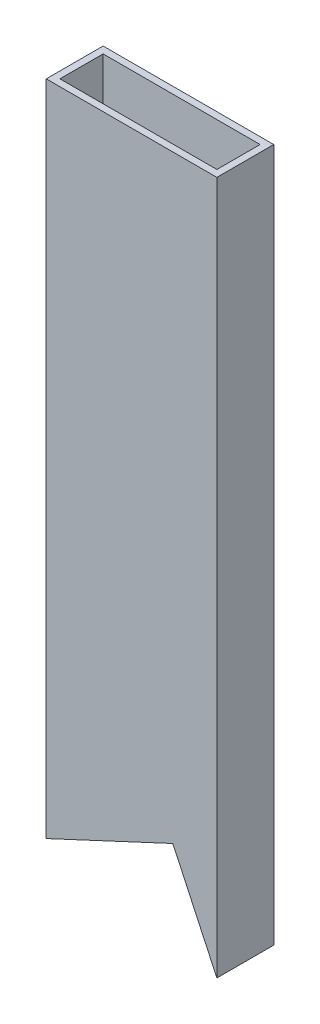
from build123d import *

# Parameters (mm, degrees)
SKETCH1_W           = 76.2
SKETCH1_H           = 25.4
SKETCH1_W_2         = 70.104
SKETCH1_H_2         = 19.304
BOSS_EXTRUDE1_DEPTH = 280
CUT_EXTRUDE1_START  = -34.530327
SKETCH3_W           = 25.4
SKETCH3_H           = 76.2
CUT_EXTRUDE1_DEPTH  = 72.630327
SKETCH5_W           = 76.2
SKETCH5_H           = 25.4
SKETCH5_W_2         = 70.104
SKETCH5_H_2         = 19.304
BOSS_EXTRUDE2_DEPTH = 38.1


with BuildPart() as part:
    # Sketch1 → Boss-Extrude1 (new body)
    with BuildSketch(Plane(origin=(0, 0, 0), x_dir=(1, 0, 0), z_dir=(0, 1, 0))):
        Rectangle(SKETCH1_W, SKETCH1_H)
        Rectangle(SKETCH1_W_2, SKETCH1_H_2, mode=Mode.SUBTRACT)
    extrude(amount=BOSS_EXTRUDE1_DEPTH)

    # Sketch3 → Cut-Extrude1 (cut)
    with BuildSketch(Plane(origin=(0, 0, 0), x_dir=(0, 0, -1), z_dir=(0.906307787, 0.422618262, 0)).offset(CUT_EXTRUDE1_START)):
        Rectangle(SKETCH3_W, SKETCH3_H)
    extrude(amount=CUT_EXTRUDE1_DEPTH, mode=Mode.SUBTRACT)

    # Sketch5 → Boss-Extrude2 (add)
    with BuildSketch(Plane(origin=(0, 280, 0), x_dir=(1, 0, 0), z_dir=(0, 1, 0))):
        Rectangle(SKETCH5_W, SKETCH5_H)
        Rectangle(SKETCH5_W_2, SKETCH5_H_2, mode=Mode.SUBTRACT)
    extrude(amount=BOSS_EXTRUDE2_DEPTH)


solid = part.part
